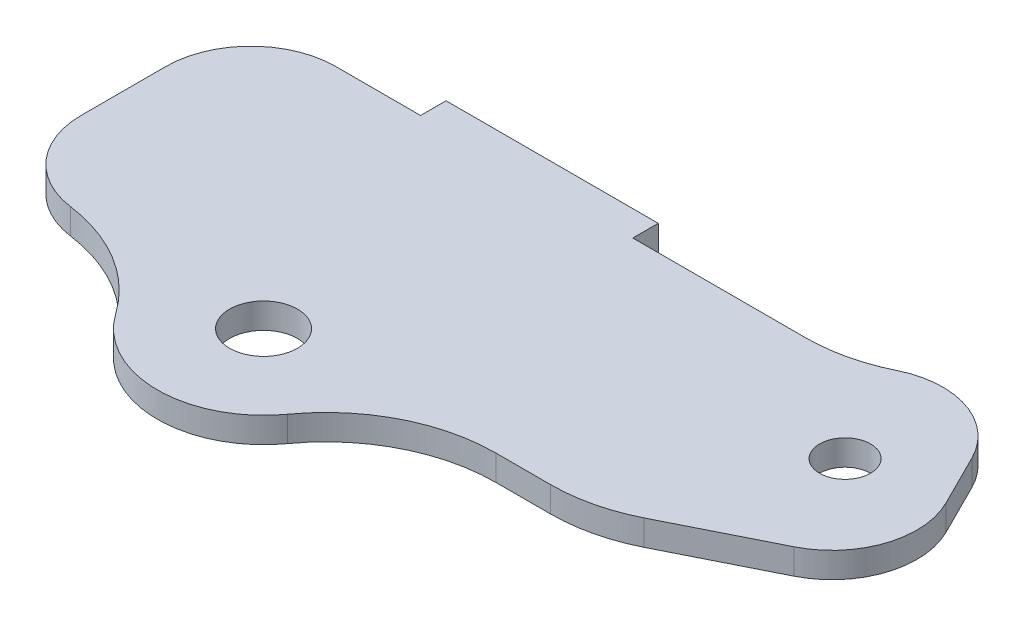
from build123d import *

# Parameters (mm, degrees)
SKETCH1_R           = 3
SKETCH1_W           = 25
SKETCH1_H           = 3
BOSS_EXTRUDE1_DEPTH = 3
FILLET1_R           = 10
FILLET2_R           = 20


with BuildPart() as part:
    # Sketch1 → Boss-Extrude1 (new body)
    with BuildSketch(Plane(origin=(0, 0, 0), x_dir=(1, 0, 0), z_dir=(0, 1, 0))):
        with BuildLine():
            Line((10, -16), (10, -15))
            Line((10, -15), (1.372983346, -15))
            ThreePointArc((1.372983346, -15), (1.468118785, -15.49598283), (1.5, -16))
            ThreePointArc((1.5, -16), (-3.00401717, -19.968118785), (-6.372983346, -15))
            Line((-6.372983346, -15), (-15, -15))
            Line((-15, -15), (-15, -16))
            ThreePointArc((-15, -16), (-2.5, -28.5), (10, -16))
        make_face()
        with BuildLine():
            Line((47.94427191, 21.472135955), (35, 15))
            Line((35, 15), (10, 15))
            Line((10, 15), (10, 12))
            Line((10, 12), (-15, 12))
            Line((-15, 12), (-15, 15))
            Line((-15, 15), (-35, 15))
            Line((-35, 15), (-35, -15))
            Line((-35, -15), (-15, -15))
            Line((-15, -15), (-6.372983346, -15))
            ThreePointArc((-6.372983346, -15), (-2.5, -12), (1.372983346, -15))
            Line((1.372983346, -15), (10, -15))
            Line((10, -15), (35, -15))
            Line((35, -15), (59.94427191, -2.527864045))
            Line((59.94427191, -2.527864045), (47.94427191, 21.472135955))
        make_face()
        with Locations((45, 5)):
            Circle(SKETCH1_R, mode=Mode.SUBTRACT)
        with Locations((-2.5, 16.5)):
            Rectangle(SKETCH1_W, SKETCH1_H)
        with Locations((-2.5, 13.5)):
            Rectangle(SKETCH1_W, SKETCH1_H)
    extrude(amount=BOSS_EXTRUDE1_DEPTH)

    # Fillet1
    fillet1_edges = [part.edges().sort_by_distance(p)[0] for p in [
        (47.94427191, 1.5, -21.472135955),
        (59.94427191, 1.5, 2.527864045),
        (-35, 1.5, 15),
        (-35, 1.5, -15),
    ]]
    fillet(fillet1_edges, radius=FILLET1_R)

    # Fillet2
    fillet2_edges = [part.edges().sort_by_distance(p)[0] for p in [
        (35, 1.5, -15),
        (35, 1.5, 15),
        (10, 1.5, 15),
        (-15, 1.5, 15),
    ]]
    fillet(fillet2_edges, radius=FILLET2_R)


solid = part.part
